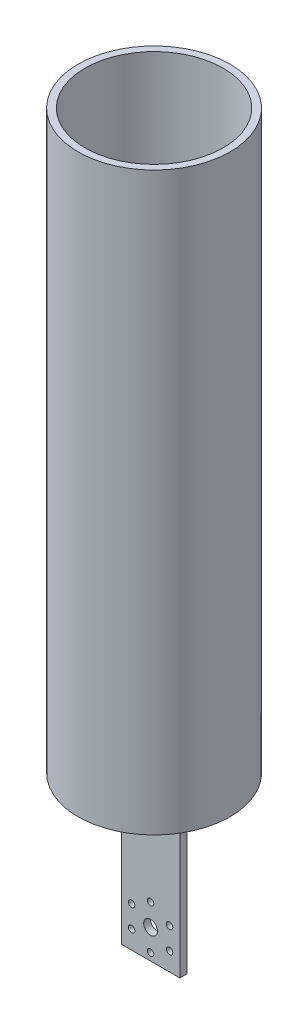
from build123d import *

# Parameters (mm, degrees)
SKETCH1_W           = 3
SKETCH1_H           = 70
BOSS_EXTRUDE1_DEPTH = 25.4
SKETCH2_R           = 3
SKETCH2_R_2         = 1.4
CUT_EXTRUDE1_DEPTH  = 25.4
BOSS_EXTRUDE2_DEPTH = 100
SKETCH4_R           = 33
SKETCH4_R_2         = 30
BOSS_EXTRUDE3_DEPTH = 250


with BuildPart() as part:
    # Sketch1 → Boss-Extrude1 (new body)
    with BuildSketch(Plane(origin=(0, 0, 0), x_dir=(0, 0, -1), z_dir=(1, 0, 0))):
        with Locations((1.5, 35)):
            Rectangle(SKETCH1_W, SKETCH1_H)
    extrude(amount=BOSS_EXTRUDE1_DEPTH)

    # Sketch2 → Cut-Extrude1 (cut)
    with BuildSketch(Plane.XY):
        with Locations((12.7, 12.7)):
            Circle(SKETCH2_R)
        with Locations((12.7, 22.2)):
            Circle(SKETCH2_R_2)
        with Locations((20.927241336, 17.45)):
            Circle(SKETCH2_R_2)
        with Locations((20.927241336, 7.95)):
            Circle(SKETCH2_R_2)
        with Locations((12.7, 3.2)):
            Circle(SKETCH2_R_2)
        with Locations((4.472758664, 7.95)):
            Circle(SKETCH2_R_2)
        with Locations((4.472758664, 17.45)):
            Circle(SKETCH2_R_2)
    extrude(amount=-CUT_EXTRUDE1_DEPTH, mode=Mode.SUBTRACT)

    # Sketch3 → Boss-Extrude2 (add)
    with BuildSketch(Plane(origin=(0, 70, 0), x_dir=(1, 0, 0), z_dir=(0, 1, 0))):
        Polygon((12.7, 0), (42.7, 0), (42.7, 3), (-17.3, 3), (-17.3, 0), align=None)
    extrude(amount=BOSS_EXTRUDE2_DEPTH)

    # Sketch4 → Boss-Extrude3 (add)
    with BuildSketch(Plane.XZ.offset(-70)):
        with Locations((12.7, -1.5)):
            Circle(SKETCH4_R)
        with Locations((12.7, -1.5)):
            Circle(SKETCH4_R_2, mode=Mode.SUBTRACT)
    extrude(amount=-BOSS_EXTRUDE3_DEPTH)


solid = part.part
